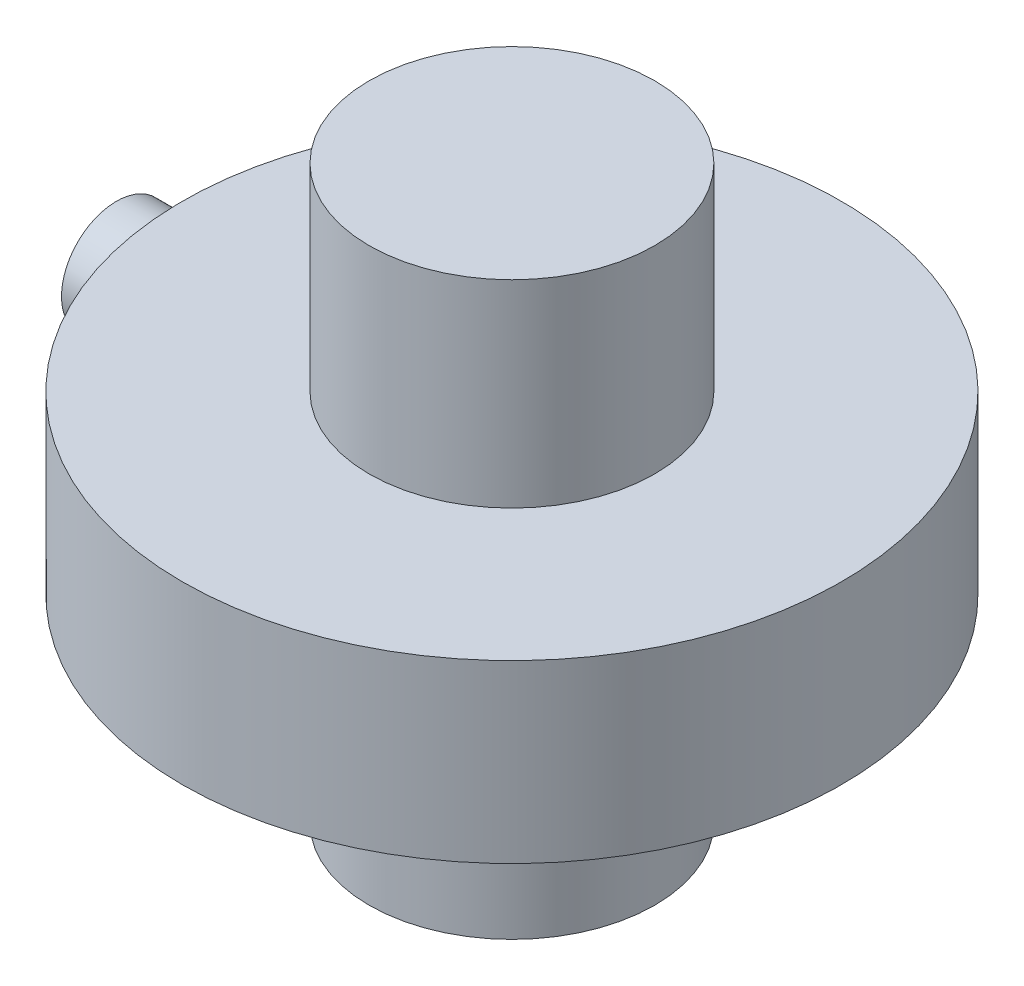
from build123d import *

# Parameters (mm, degrees)
SKETCH1_R           = 5
BOSS_EXTRUDE1_DEPTH = 10
SKETCH4_R           = 30
BOSS_EXTRUDE4_DEPTH = 8
SKETCH5_R           = 13
BOSS_EXTRUDE5_DEPTH = 26


with BuildPart() as part:
    # Sketch1 → Boss-Extrude1 (new body)
    with BuildSketch(Plane(origin=(0, 0, 0), x_dir=(0, 0, -1), z_dir=(1, 0, 0))):
        Circle(SKETCH1_R)
    extrude(amount=BOSS_EXTRUDE1_DEPTH)


with BuildPart() as body_2:
    # Sketch4 → Boss-Extrude4 (new body, symmetric)
    with BuildSketch(Plane(origin=(0, 0, 0), x_dir=(1, 0, 0), z_dir=(0, 1, 0))):
        with Locations((36, 0)):
            Circle(SKETCH4_R)
    extrude(amount=BOSS_EXTRUDE4_DEPTH, both=True)

    # Sketch5 → Boss-Extrude5 (add, symmetric)
    with BuildSketch(Plane(origin=(0, 0, 0), x_dir=(1, 0, 0), z_dir=(0, 1, 0))):
        with Locations((36, 0)):
            Circle(SKETCH5_R)
    extrude(amount=BOSS_EXTRUDE5_DEPTH, both=True)


solid = Compound([part.part, body_2.part])
